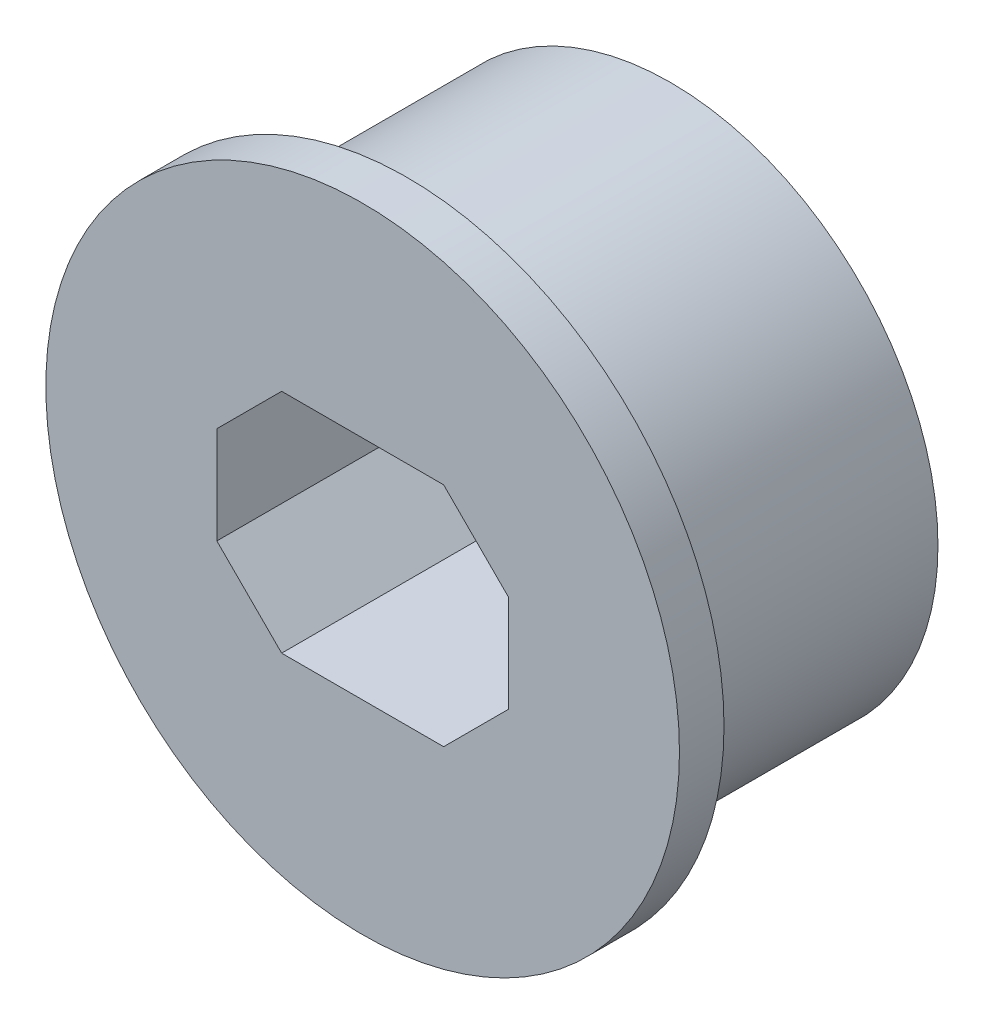
from build123d import *

# Parameters (mm, degrees)
SKETCH1_R           = 4.1275
BOSS_EXTRUDE2_DEPTH = 4.064
SKETCH2_R           = 4.8895
BOSS_EXTRUDE3_DEPTH = 1.5875
SKETCH7_W           = 4.5
SKETCH7_H           = 3.5
CUT_EXTRUDE2_DEPTH  = 6.6515
CHAMFER1_SIZE       = 1
SKETCH8_R           = 4.8895
CUT_EXTRUDE3_DEPTH  = 0.9


with BuildPart() as part:
    # Sketch1 → Boss-Extrude2 (new body)
    with BuildSketch(Plane.XY):
        with Locations((6.731, -165.7192297)):
            Circle(SKETCH1_R)
    extrude(amount=-BOSS_EXTRUDE2_DEPTH)

    # Sketch2 → Boss-Extrude3 (add)
    with BuildSketch(Plane.XY):
        with Locations((6.731, -165.7192297)):
            Circle(SKETCH2_R)
    extrude(amount=BOSS_EXTRUDE3_DEPTH)

    # Sketch7 → Cut-Extrude2 (cut, through all)
    with BuildSketch(Plane(origin=(0, 0, -4.064), x_dir=(-1, 0, 0), z_dir=(0, 0, -1))):
        with Locations((-6.731, -165.7192297)):
            Rectangle(SKETCH7_W, SKETCH7_H)
    extrude(amount=-CUT_EXTRUDE2_DEPTH, mode=Mode.SUBTRACT)

    # Chamfer1
    chamfer1_edges = [part.edges().sort_by_distance(p)[0] for p in [
        (4.481, -163.9692297, -1.23825),
        (4.481, -167.4692297, -1.23825),
        (8.981, -167.4692297, -1.23825),
        (8.981, -163.9692297, -1.23825),
    ]]
    chamfer(chamfer1_edges, length=CHAMFER1_SIZE)

    # Sketch8 → Cut-Extrude3 (cut)
    with BuildSketch(Plane.XY.offset(1.5875)):
        with Locations((6.731, -165.7192297)):
            Circle(SKETCH8_R)
    extrude(amount=-CUT_EXTRUDE3_DEPTH, mode=Mode.SUBTRACT)


solid = part.part
